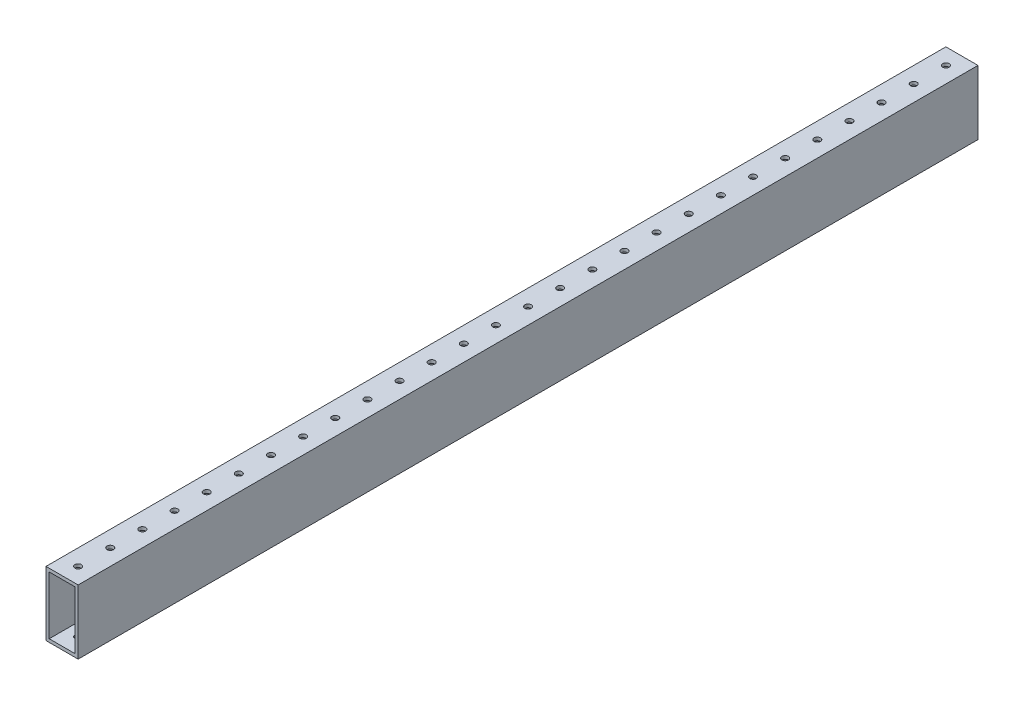
from build123d import *

# Parameters (mm, degrees)
SKETCH1_W           = 25.4
SKETCH1_H           = 50.8
SKETCH1_W_2         = 20.32
SKETCH1_H_2         = 45.72
BOSS_EXTRUDE1_DEPTH = 711.2
SKETCH2_R           = 2.54
CUT_EXTRUDE1_DEPTH  = 51.8
LPATTERN1_COUNT     = 28
LPATTERN1_PITCH     = 25.4


with BuildPart() as part:
    # Sketch1 → Boss-Extrude1 (new body)
    with BuildSketch(Plane.XY):
        with Locations((12.7, 25.4)):
            Rectangle(SKETCH1_W, SKETCH1_H)
        with Locations((12.7, 25.4)):
            Rectangle(SKETCH1_W_2, SKETCH1_H_2, mode=Mode.SUBTRACT)
    extrude(amount=BOSS_EXTRUDE1_DEPTH)

    # Sketch2 → Cut-Extrude1 (cut, through all)
    with BuildSketch(Plane(origin=(0, 50.8, 0), x_dir=(1, 0, 0), z_dir=(0, 1, 0))):
        with Locations((12.7, -698.5)):
            Circle(SKETCH2_R)
    cut_extrude1 = extrude(amount=-CUT_EXTRUDE1_DEPTH, mode=Mode.SUBTRACT)

    # LPattern1: Cut-Extrude1 ×28
    with Locations(*[(0, 0, -i * LPATTERN1_PITCH) for i in range(1, LPATTERN1_COUNT)]):
        add(cut_extrude1, mode=Mode.SUBTRACT)


solid = part.part
